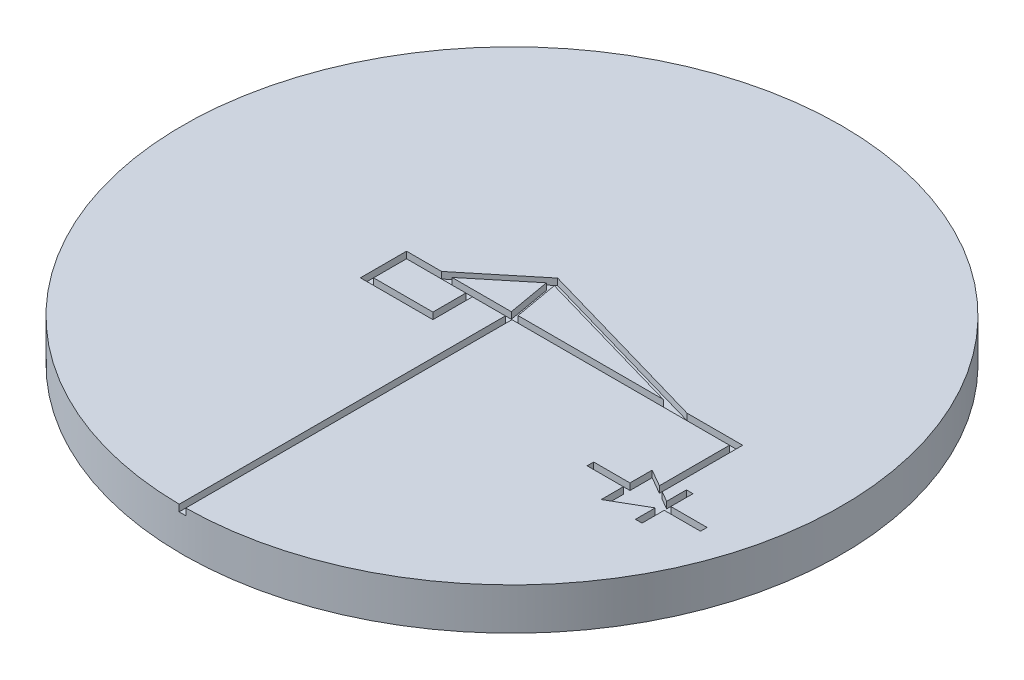
from build123d import *

# Parameters (mm, degrees)
SKETCH1_R           = 25
BOSS_EXTRUDE1_DEPTH = 3.175
SKETCH2_W           = 4.5
SKETCH2_H           = 2.5
CUT_EXTRUDE1_DEPTH  = 0.5


with BuildPart() as part:
    # Sketch1 → Boss-Extrude1 (new body)
    with BuildSketch(Plane(origin=(0, 0, 0), x_dir=(1, 0, 0), z_dir=(0, 1, 0))):
        Circle(SKETCH1_R)
    extrude(amount=BOSS_EXTRUDE1_DEPTH)

    # Sketch2 → Cut-Extrude1 (cut)
    with BuildSketch(Plane(origin=(0, 3.175, 0), x_dir=(1, 0, 0), z_dir=(0, 1, 0))):
        with BuildLine():
            Line((17.25, 0.25), (17.25, -5.855662433))
            Line((17.25, -5.855662433), (18.049038106, -6.316987298))
            Line((18.049038106, -6.316987298), (18.049038106, -5.25))
            Line((18.049038106, -5.25), (18.049038106, -4.816987298))
            Line((18.049038106, -4.816987298), (18.549038106, -4.816987298))
            Line((18.549038106, -4.816987298), (18.549038106, -5.25))
            Line((18.549038106, -5.25), (18.549038106, -6.5))
            Line((18.549038106, -6.5), (21.299038106, -6.5))
            Line((21.299038106, -6.5), (21.299038106, -7))
            Line((21.299038106, -7), (18.549038106, -7))
            Line((18.549038106, -7), (18.549038106, -8.25))
            Line((18.549038106, -8.25), (18.549038106, -8.683012702))
            Line((18.549038106, -8.683012702), (18.049038106, -8.683012702))
            Line((18.049038106, -8.683012702), (18.049038106, -8.25))
            Line((18.049038106, -8.25), (18.049038106, -7.183012702))
            Line((18.049038106, -7.183012702), (15.450961894, -8.683012702))
            Line((15.450961894, -8.683012702), (15.450961894, -7))
            Line((15.450961894, -7), (12.700961894, -7))
            Line((12.700961894, -7), (12.700961894, -6.5))
            Line((12.700961894, -6.5), (15.450961894, -6.5))
            Line((15.450961894, -6.5), (15.450961894, -4.816987298))
            Line((15.450961894, -4.816987298), (16.75, -5.566987298))
            Line((16.75, -5.566987298), (16.75, -0.25))
            Line((16.75, -0.25), (0.25, -0.25))
            Line((0.25, -0.25), (0.25, -24.998749969))
            ThreePointArc((0.25, -24.998749969), (0, -25), (-0.25, -24.998749969))
            Line((-0.25, -24.998749969), (-0.25, -0.25))
            Line((-0.25, -0.25), (-2.75, -0.25))
            Line((-2.75, -0.25), (-2.75, -3.25))
            Line((-2.75, -3.25), (-8.25, -3.25))
            Line((-8.25, -3.25), (-8.25, 0.25))
            Line((-8.25, 0.25), (-5.589373118, 0.25))
            Line((-5.589373118, 0.25), (-0.853083665, 4.132571689))
            Line((-0.853083665, 4.132571689), (-0.751596944, 4.215765395))
            Line((-0.751596944, 4.215765395), (-0.625482869, 4.179488852))
            Line((-0.625482869, 4.179488852), (13.035241579, 0.25))
            Line((13.035241579, 0.25), (17.25, 0.25))
        make_face()
        Polygon((-4.800684576, 0.25), (-0.297938398, 0.25), (-0.866588339, 3.47497407), align=None, mode=Mode.SUBTRACT)
        Polygon((0.209774908, 0.25), (-0.378852437, 3.588271558), (11.226526686, 0.25), align=None, mode=Mode.SUBTRACT)
        with Locations((-5.5, -1.5)):
            Rectangle(SKETCH2_W, SKETCH2_H, mode=Mode.SUBTRACT)
    extrude(amount=-CUT_EXTRUDE1_DEPTH, mode=Mode.SUBTRACT)


solid = part.part
